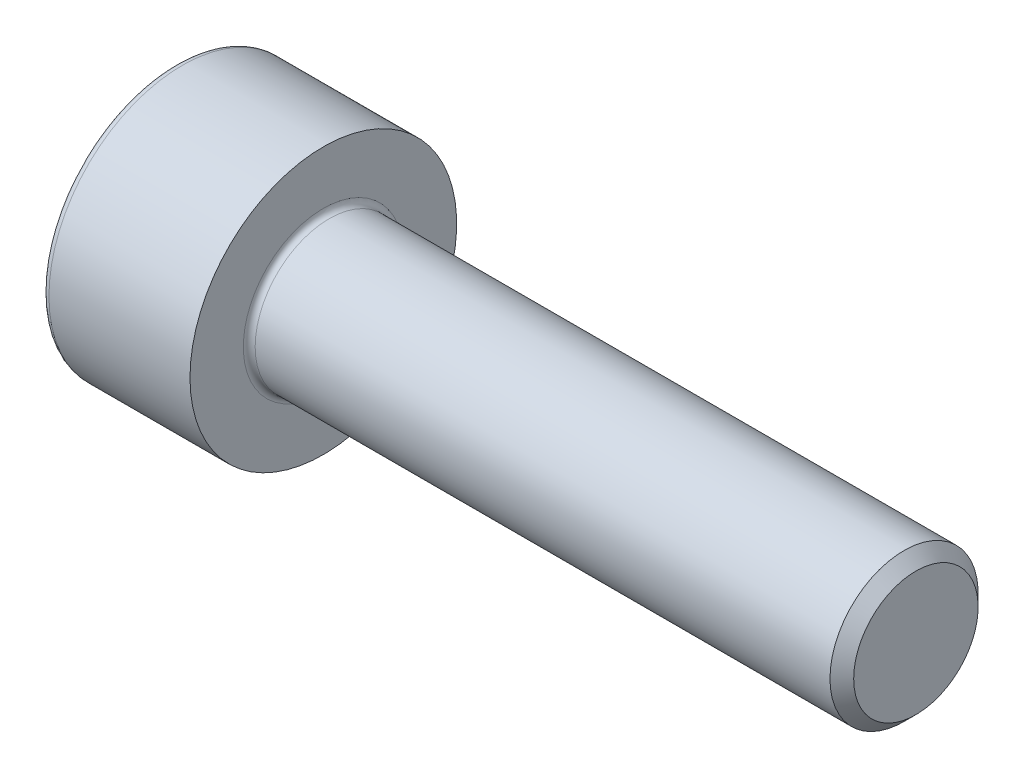
from build123d import *

# Parameters (mm, degrees)
FILLET1_R      = 0.1
FILLET2_R      = 0.12
CHAMFER1_SIZE  = 0.2
EXTRUDE1_DEPTH = 1.1


with BuildPart() as part:
    # Sketch1 → Revolve1 (revolve)
    with BuildSketch(Plane.XY, mode=Mode.PRIVATE) as revolve1_sk:
        Polygon((2.5, 1.25), (2.5, 0), (4.279914881, 0), (12.5, 0), (12.5, 1.25), align=None)
        Polygon((0, 2.25), (0, 0), (2.5, 0), (2.5, 1.25), (2.5, 2.25), align=None)
    revolve(revolve1_sk.sketch.rotate(Axis((0, 0, 0), (1, 0, 0)), 90), axis=Axis((0, 0, 0), (1, 0, 0)))

    # Fillet1
    fillet1_edges = [part.edges().sort_by_distance(p)[0] for p in [
        (2.5, 0, -1.25),
    ]]
    fillet(fillet1_edges, radius=FILLET1_R)

    # Fillet2
    fillet2_edges = [part.edges().sort_by_distance(p)[0] for p in [
        (0, 0, -2.25),
    ]]
    fillet(fillet2_edges, radius=FILLET2_R)

    # Chamfer1
    chamfer1_edges = [part.edges().sort_by_distance(p)[0] for p in [
        (12.5, 0, -1.25),
    ]]
    chamfer(chamfer1_edges, length=CHAMFER1_SIZE)

    # Sketch2 → Extrude1 (cut)
    with BuildSketch(Plane.ZY):
        Polygon((0, 1.154700538), (-1, 0.577350269), (-1, -0.577350269), (0, -1.154700538), (1, -0.577350269), (1, 0.577350269), align=None)
    extrude(amount=-EXTRUDE1_DEPTH, mode=Mode.SUBTRACT)


solid = part.part
